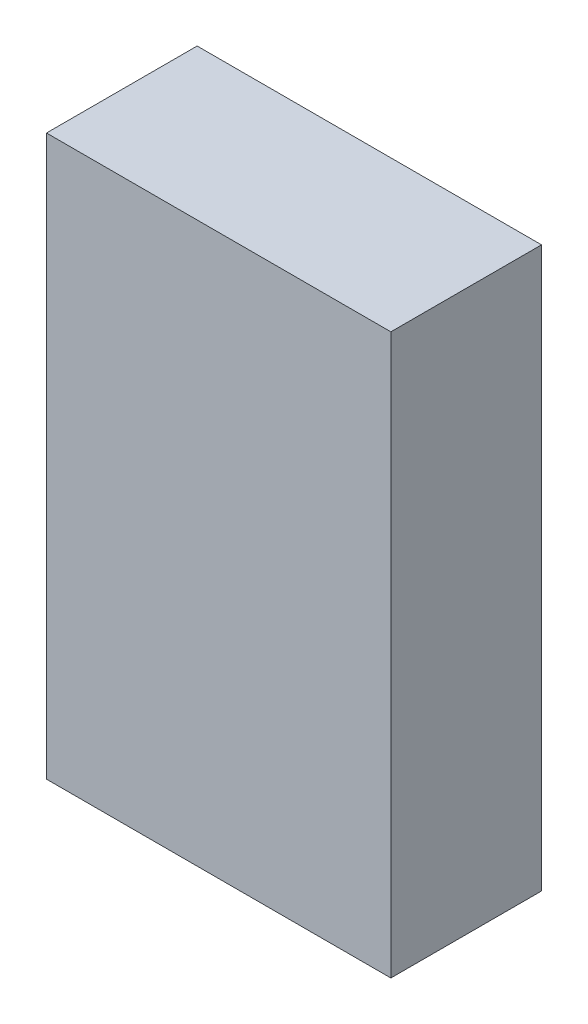
from build123d import *

# Parameters (mm, degrees)
SKETCH1_W           = 16
SKETCH1_H           = 26
BOSS_EXTRUDE1_DEPTH = 3.5
SKETCH2_W           = 16
SKETCH2_H           = 26
BOSS_EXTRUDE2_DEPTH = 3.5
SKETCH3_R           = 5
CUT_EXTRUDE1_DEPTH  = 2.5


with BuildPart() as part:
    # Sketch1 → Boss-Extrude1 (new body)
    with BuildSketch(Plane.XY):
        with Locations((8, 13)):
            Rectangle(SKETCH1_W, SKETCH1_H)
        with BuildLine():
            Line((13.25, 23.790620927), (13.25, 2.209379073))
            ThreePointArc((13.25, 2.209379073), (8, 1), (2.75, 2.209379073))
            Line((2.75, 2.209379073), (2.75, 23.790620927))
            ThreePointArc((2.75, 23.790620927), (8, 25), (13.25, 23.790620927))
        make_face(mode=Mode.SUBTRACT)
    extrude(amount=BOSS_EXTRUDE1_DEPTH)

    # Sketch2 → Boss-Extrude2 (add)
    with BuildSketch(Plane.XY.offset(3.5)):
        with Locations((8, 13)):
            Rectangle(SKETCH2_W, SKETCH2_H)
    extrude(amount=BOSS_EXTRUDE2_DEPTH)

    # Sketch3 → Cut-Extrude1 (cut)
    with BuildSketch(Plane(origin=(0, 0, 3.5), x_dir=(-1, 0, 0), z_dir=(0, 0, -1))):
        with Locations((-8, 13)):
            Circle(SKETCH3_R)
    extrude(amount=-CUT_EXTRUDE1_DEPTH, mode=Mode.SUBTRACT)


solid = part.part
